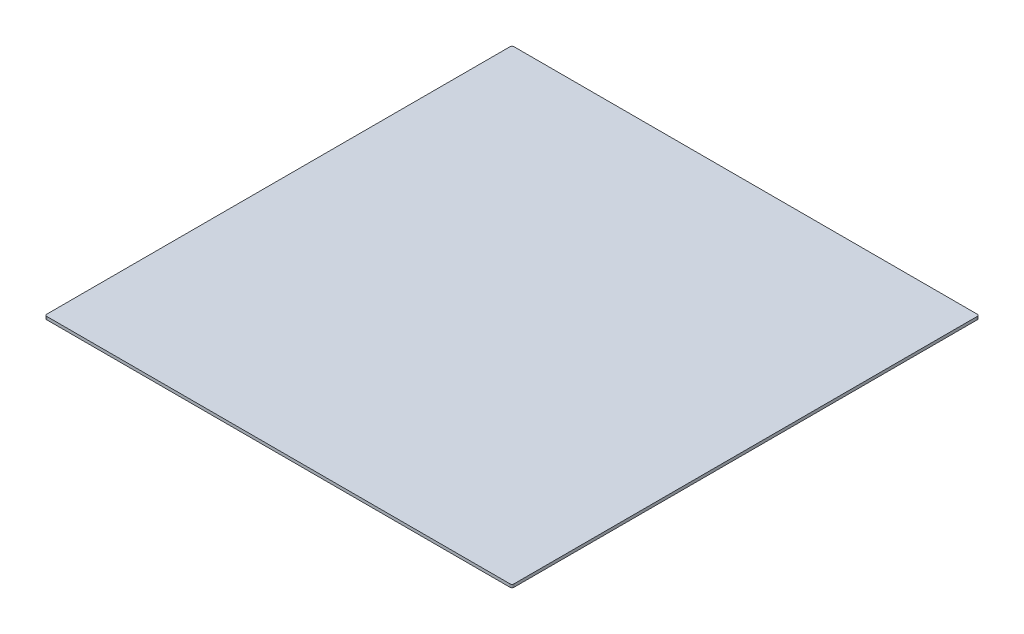
from build123d import *

# Parameters (mm, degrees)
BOSS_EXTRUDE1_DEPTH = 3


with BuildPart() as part:
    # Sketch2 → Boss-Extrude1 (new body)
    with BuildSketch(Plane(origin=(0, 0, 0), x_dir=(1, 0, 0), z_dir=(0, 1, 0))):
        with BuildLine():
            Line((-232.5, -234.5), (232.5, -234.5))
            ThreePointArc((232.5, -234.5), (233.914213562, -233.914213562), (234.5, -232.5))
            Line((234.5, -232.5), (234.5, 232.5))
            ThreePointArc((234.5, 232.5), (233.914213562, 233.914213562), (232.5, 234.5))
            Line((232.5, 234.5), (-232.5, 234.5))
            ThreePointArc((-232.5, 234.5), (-233.914213562, 233.914213562), (-234.5, 232.5))
            Line((-234.5, 232.5), (-234.5, -232.5))
            ThreePointArc((-234.5, -232.5), (-233.914213562, -233.914213562), (-232.5, -234.5))
        make_face()
    extrude(amount=BOSS_EXTRUDE1_DEPTH)


solid = part.part
